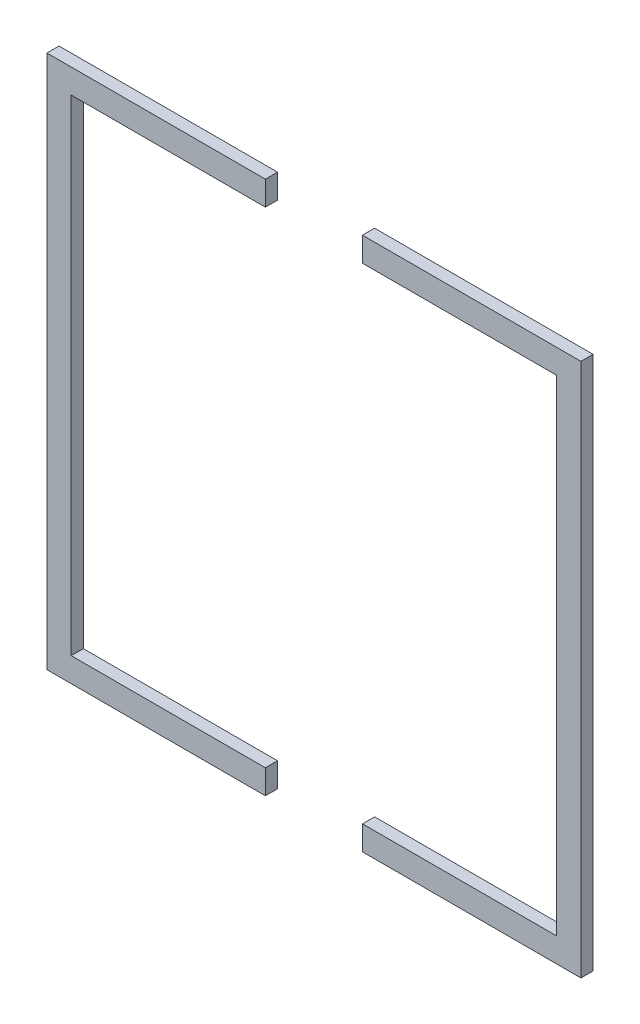
from build123d import *

# Parameters (mm, degrees)
BOSS_EXTRUDE1_DEPTH   = 3.175
BOSS_EXTRUDE1_2_DEPTH = 3.175


with BuildPart() as part:
    # Sketch1 → Boss-Extrude1 (new body)
    with BuildSketch(Plane.XY):
        Polygon((57.15, 6.35), (57.15, 0), (0, 0), (0, 139.7), (57.15, 139.7), (57.15, 133.35), (6.35, 133.35), (6.35, 6.35), align=None)
    extrude(amount=BOSS_EXTRUDE1_DEPTH)


with BuildPart() as body_2:
    # Sketch1 → Boss-Extrude1 2 (new body)
    with BuildSketch(Plane.XY):
        Polygon((82.55, 0), (139.7, 0), (139.7, 139.7), (82.55, 139.7), (82.55, 133.35), (133.35, 133.35), (133.35, 6.35), (82.55, 6.35), align=None)
    extrude(amount=BOSS_EXTRUDE1_2_DEPTH)


solid = Compound([part.part, body_2.part])
